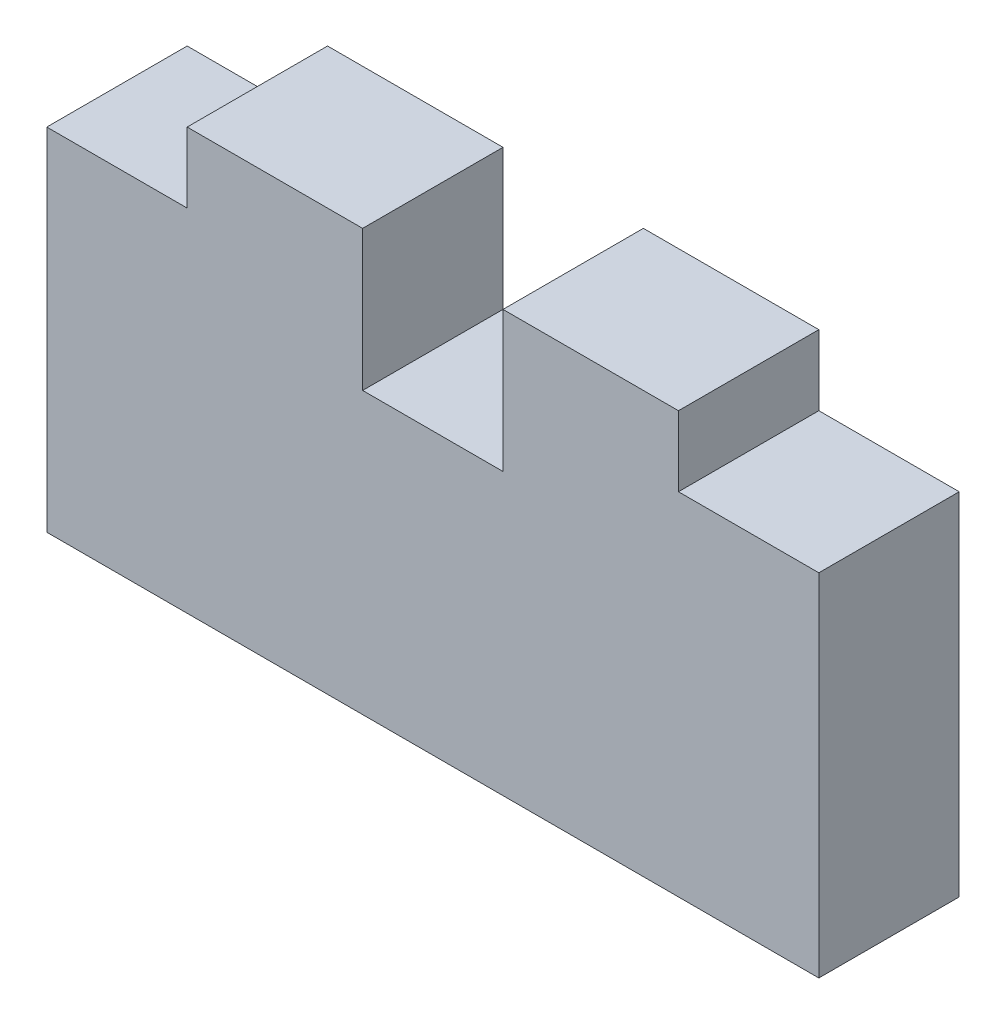
from build123d import *

# Parameters (mm, degrees)
BOSS_EXTRUDE2_DEPTH = 3.175


with BuildPart() as part:
    # Sketch1 → Boss-Extrude2 (new body)
    with BuildSketch(Plane.XY):
        Polygon((0, 0), (17.4625, 0), (17.4625, 7.9375), (14.2875, 7.9375), (14.2875, 9.525), (10.31875, 9.525), (10.31875, 6.35), (7.14375, 6.35), (7.14375, 9.525), (3.175, 9.525), (3.175, 7.9375), (0, 7.9375), align=None)
    extrude(amount=BOSS_EXTRUDE2_DEPTH)


solid = part.part
